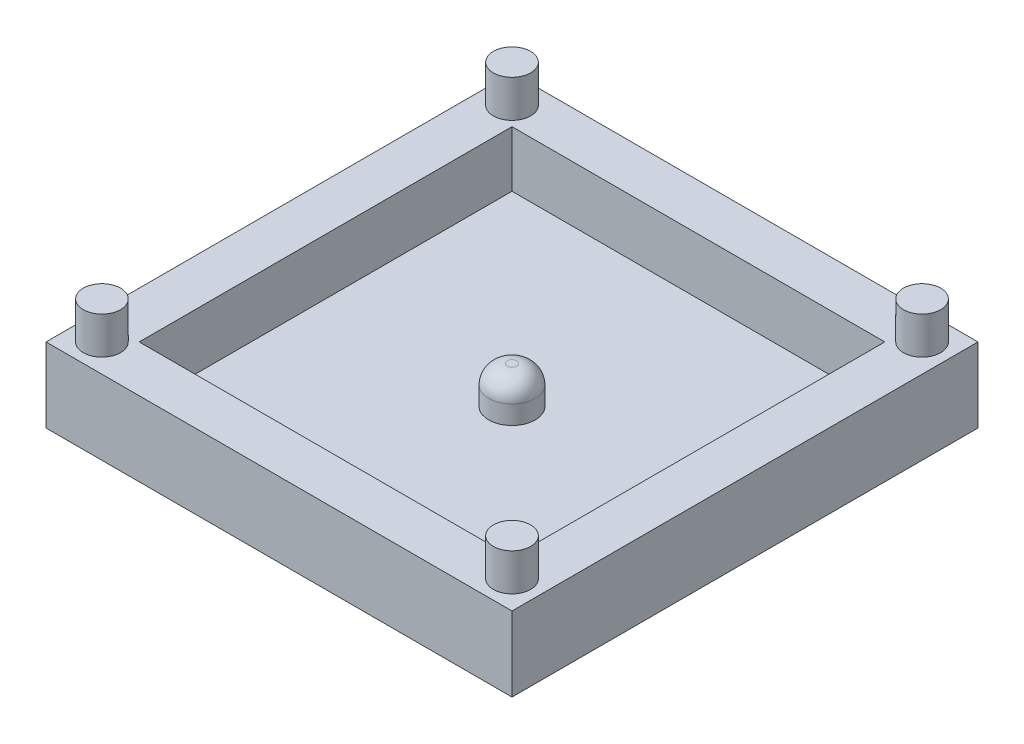
from build123d import *

# Parameters (mm, degrees)
SKETCH1_W           = 25
SKETCH1_H           = 25
BOSS_EXTRUDE1_DEPTH = 4
SKETCH2_W           = 20
SKETCH2_H           = 20
CUT_EXTRUDE1_DEPTH  = 3
SKETCH3_R           = 1.25
BOSS_EXTRUDE2_DEPTH = 2
FILLET1_R           = 1
SKETCH4_R           = 1
BOSS_EXTRUDE3_DEPTH = 2


with BuildPart() as part:
    # Sketch1 → Boss-Extrude1 (new body)
    with BuildSketch(Plane(origin=(0, 0, 0), x_dir=(1, 0, 0), z_dir=(0, 1, 0))):
        Rectangle(SKETCH1_W, SKETCH1_H)
    extrude(amount=BOSS_EXTRUDE1_DEPTH)

    # Sketch2 → Cut-Extrude1 (cut)
    with BuildSketch(Plane(origin=(0, 4, 0), x_dir=(1, 0, 0), z_dir=(0, 1, 0))):
        Rectangle(SKETCH2_W, SKETCH2_H)
    extrude(amount=-CUT_EXTRUDE1_DEPTH, mode=Mode.SUBTRACT)

    # Sketch3 → Boss-Extrude2 (add)
    with BuildSketch(Plane(origin=(0, 1, 0), x_dir=(1, 0, 0), z_dir=(0, 1, 0))):
        Circle(SKETCH3_R)
    extrude(amount=BOSS_EXTRUDE2_DEPTH)

    # Fillet1
    fillet1_edges = [part.edges().sort_by_distance(p)[0] for p in [
        (-1.25, 3, 0),
    ]]
    fillet(fillet1_edges, radius=FILLET1_R)

    # Sketch4 → Boss-Extrude3 (add)
    with BuildSketch(Plane(origin=(0, 4, 0), x_dir=(1, 0, 0), z_dir=(0, 1, 0))):
        with Locations((-11, 11)):
            Circle(SKETCH4_R)
        with Locations((11, 11)):
            Circle(SKETCH4_R)
        with Locations((11, -11)):
            Circle(SKETCH4_R)
        with Locations((-11, -11)):
            Circle(SKETCH4_R)
    extrude(amount=BOSS_EXTRUDE3_DEPTH)


solid = part.part
